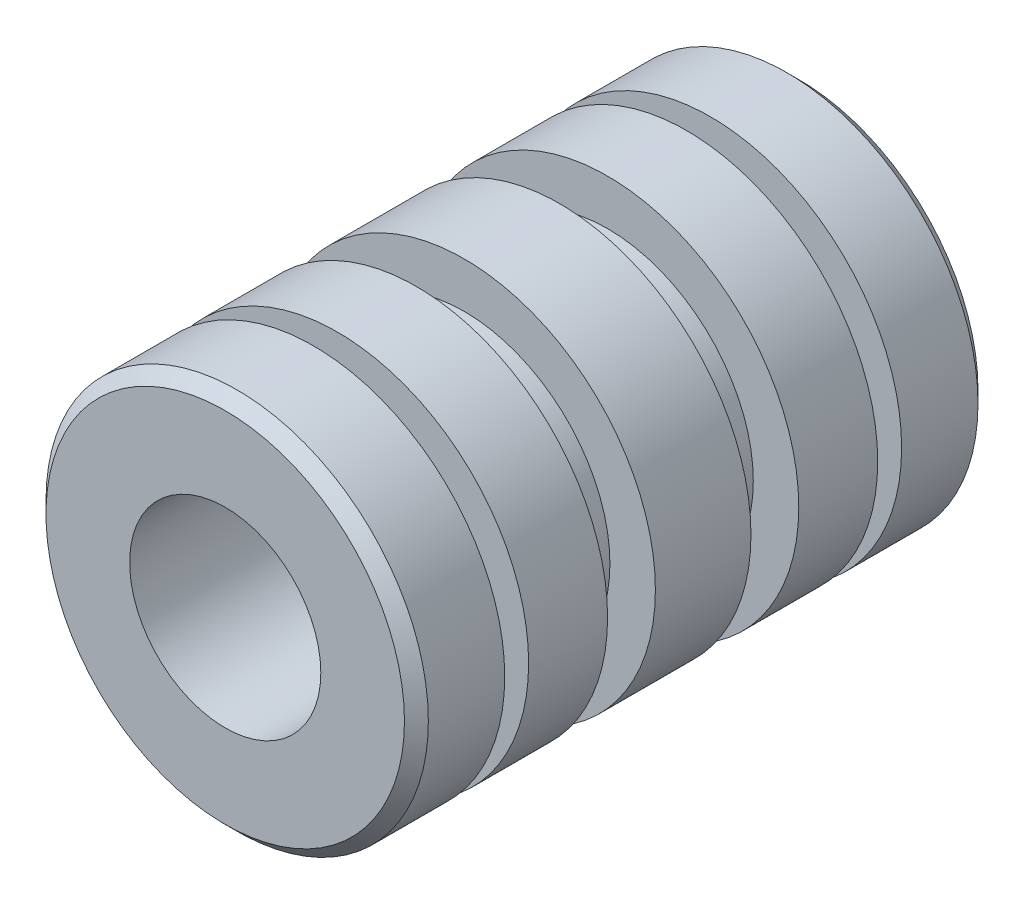
from build123d import *

# Parameters (mm, degrees)
SKETCH2_R           = 6.35
BOSS_EXTRUDE1_DEPTH = 19.05
SKETCH3_R           = 3.175
CUT_EXTRUDE1_DEPTH  = 20.05
SKETCH4_W           = 3.175
SKETCH4_H           = 0.79375
CHAMFER1_SIZE       = 0.396875
SKETCH5_W           = 3.020451336
SKETCH5_H           = 1.5875


with BuildPart() as part:
    # Sketch2 → Boss-Extrude1 (new body)
    with BuildSketch(Plane.XY):
        Circle(SKETCH2_R)
    extrude(amount=BOSS_EXTRUDE1_DEPTH)

    # Sketch3 → Cut-Extrude1 (cut, through all)
    with BuildSketch(Plane.XY.offset(19.05)):
        Circle(SKETCH3_R)
    extrude(amount=-CUT_EXTRUDE1_DEPTH, mode=Mode.SUBTRACT)

    # Sketch4 → Cut-Revolve1 (revolve, cut)
    with BuildSketch(Plane(origin=(0, 0, 0), x_dir=(1, 0, 0), z_dir=(0, 1, 0))):
        with Locations((6.329219641, -15.719425)):
            Rectangle(SKETCH4_W, SKETCH4_H)
        with Locations((6.329219641, -3.330575)):
            Rectangle(SKETCH4_W, SKETCH4_H)
    revolve(axis=Axis((0, 0, 19.05), (0, 0, -1)), mode=Mode.SUBTRACT)

    # Chamfer1
    chamfer1_edges = [part.edges().sort_by_distance(p)[0] for p in [
        (-6.35, 0, 0),
        (-6.35, 0, 19.05),
    ]]
    chamfer(chamfer1_edges, length=CHAMFER1_SIZE)

    # Sketch5 → Cut-Revolve2 (revolve, cut)
    with BuildSketch(Plane(origin=(0, 0, 0), x_dir=(1, 0, 0), z_dir=(0, 1, 0))):
        with Locations((6.35, -11.90625)):
            Rectangle(SKETCH5_W, SKETCH5_H)
        with Locations((6.35, -7.14375)):
            Rectangle(SKETCH5_W, SKETCH5_H)
    revolve(axis=Axis((0, 0, 19.05), (0, 0, -1)), mode=Mode.SUBTRACT)


solid = part.part
